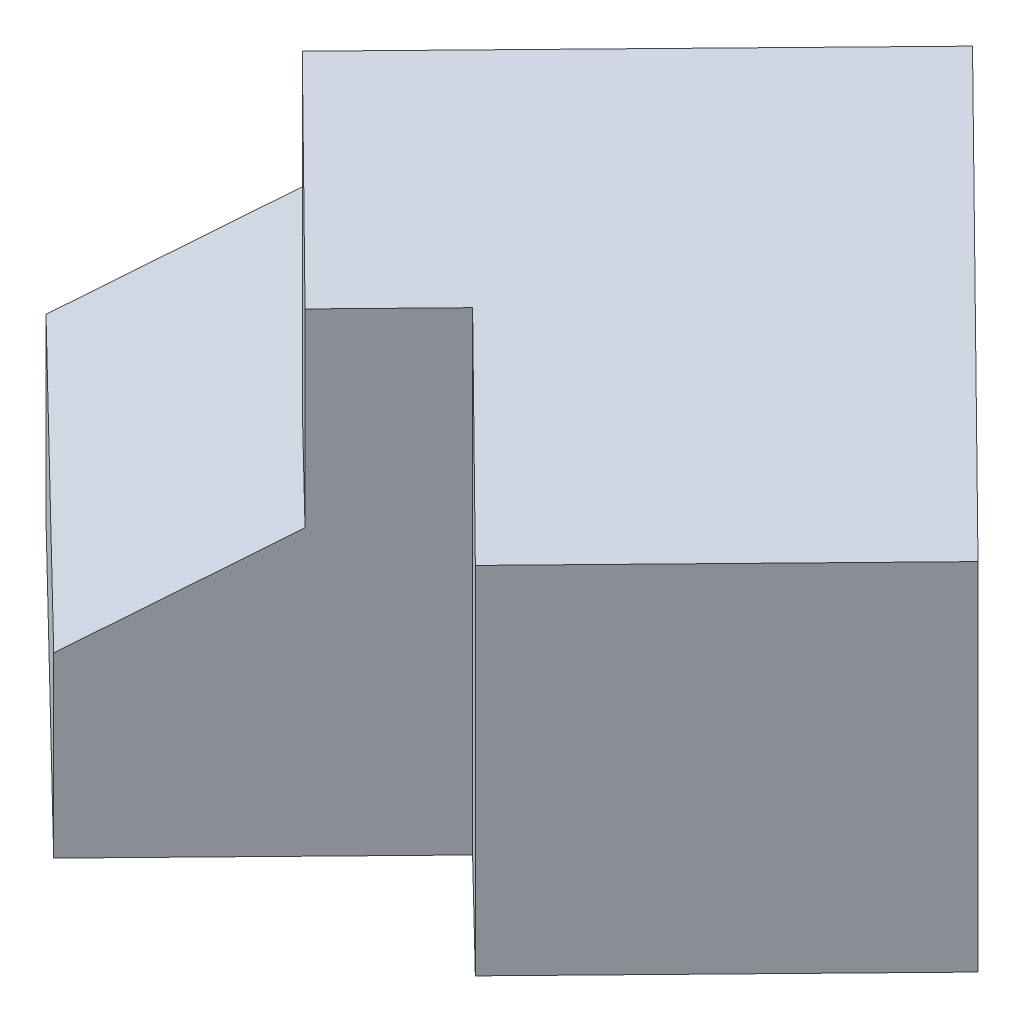
from build123d import *

# Parameters (mm, degrees)
EXTRUDE1_DEPTH = 60
EXTRUDE2_DEPTH = 95.991377429
EXTRUDE3_DEPTH = 100
EXTRUDE4_DEPTH = 100


with BuildPart() as part:
    # Sketch1 → Extrude1 (new body)
    with BuildSketch(Plane(origin=(0, 0, 0), x_dir=(1, 0, 0), z_dir=(0, 1, 0))):
        Polygon((0, 0), (-50.143211133, 48.843201956), (-15.255209736, 84.659781336), (34.888001397, 35.816579381), align=None)
    extrude(amount=EXTRUDE1_DEPTH)

    # Sketch2 → Extrude2 (cut, through all)
    with BuildSketch(Plane(origin=(0, 0, 0), x_dir=(0.697760028, 0, -0.716331588), z_dir=(0.716331588, 0, 0.697760028))):
        Polygon((50, 60), (0, 30), (0, 60), align=None)
    extrude(amount=-EXTRUDE2_DEPTH, mode=Mode.SUBTRACT)

    # Sketch3 → Extrude3 (add)
    with BuildSketch(Plane(origin=(0, 0, 0), x_dir=(1, 0, 0), z_dir=(0, 1, 0))):
        Polygon((20.932800838, 21.489947628), (3.024511148, 38.933948327), (58.845313383, 96.240475336), (94.661892763, 61.352473939), (52.796291087, 18.372578682), (34.888001397, 35.816579381), align=None)
    extrude(amount=EXTRUDE3_DEPTH)

    # Sketch4 → Extrude4 (cut)
    with BuildSketch(Plane(origin=(20.932800838, 0, -21.489947628), x_dir=(0.716331588, 0, 0.697760028), z_dir=(-0.697760028, 0, 0.716331588))):
        Polygon((25, 60), (-25, 100), (25, 100), align=None)
    extrude(amount=-EXTRUDE4_DEPTH, mode=Mode.SUBTRACT)


solid = part.part
